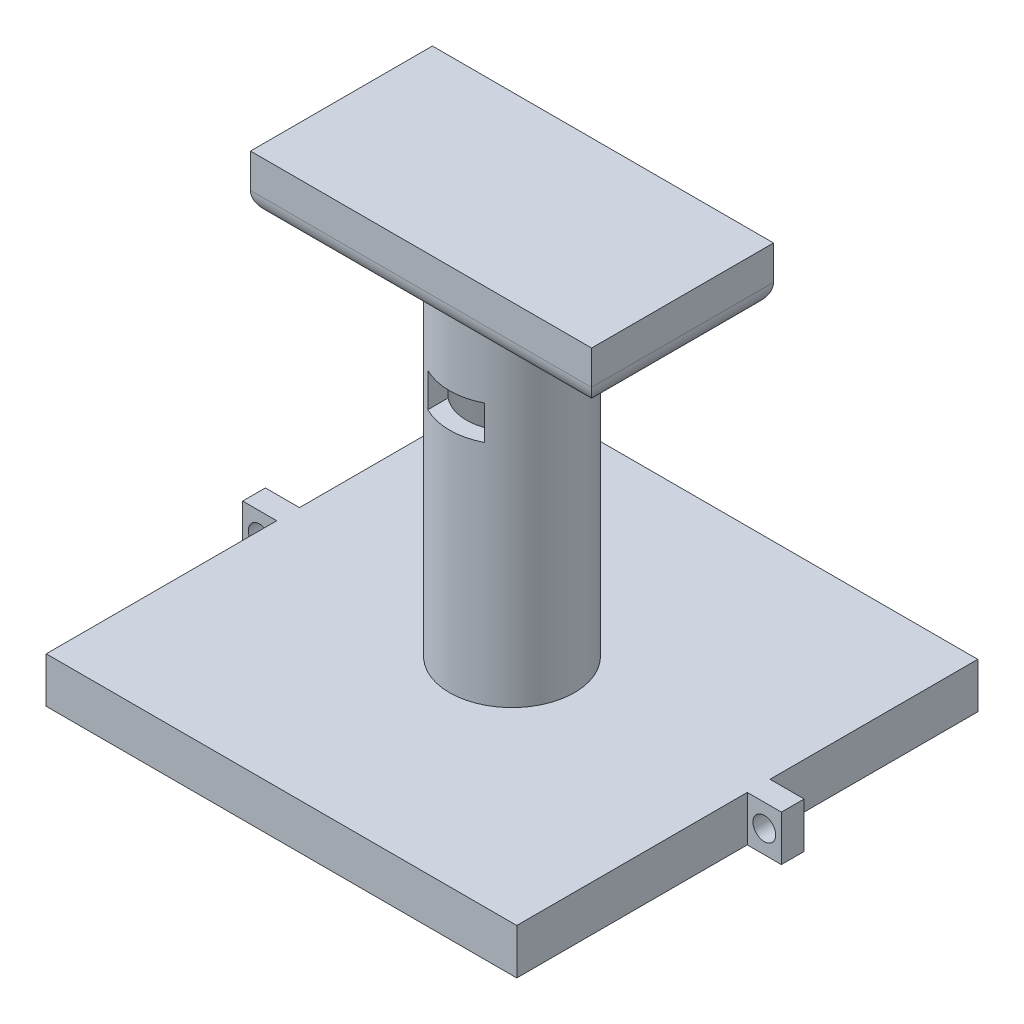
from build123d import *

# Parameters (mm, degrees)
SKETCH2_W           = 52.5507204
SKETCH2_H           = 51.48598542
SKETCH2_W_2         = 3.81
SKETCH2_H_2         = 2.54
BOSS_EXTRUDE1_DEPTH = 5.08
SKETCH3_W           = 47.4707204
SKETCH3_H           = 46.40598542
CUT_EXTRUDE1_DEPTH  = 3.81
SKETCH4_R           = 1.27
CUT_EXTRUDE2_DEPTH  = 3.302
SKETCH5_R           = 5.08
CUT_EXTRUDE3_DEPTH  = 1.9304
SKETCH6_R           = 6.985
BOSS_EXTRUDE2_DEPTH = 38.1
SKETCH8_R           = 5.08
CUT_EXTRUDE4_DEPTH  = 38.1
SKETCH7_W           = 38.1
SKETCH7_H           = 20.32
BOSS_EXTRUDE3_DEPTH = 6.35
FILLET3_R           = 2.54
SKETCH9_W           = 6.35
SKETCH9_H           = 3.81
CUT_EXTRUDE5_DEPTH  = 11.938


with BuildPart() as part:
    # Sketch2 → Boss-Extrude1 (new body)
    with BuildSketch(Plane(origin=(0, 0, 0), x_dir=(1, 0, 0), z_dir=(0, 1, 0))):
        with Locations((0, 3.81e-06)):
            Rectangle(SKETCH2_W, SKETCH2_H)
        with Locations((28.1803602, 1.27)):
            Rectangle(SKETCH2_W_2, SKETCH2_H_2)
        with Locations((-28.1803602, 1.2700127)):
            Rectangle(SKETCH2_W_2, SKETCH2_H_2)
    extrude(amount=BOSS_EXTRUDE1_DEPTH)

    # Sketch3 → Cut-Extrude1 (cut)
    with BuildSketch(Plane.XZ):
        with Locations((0, -3.81e-06)):
            Rectangle(SKETCH3_W, SKETCH3_H)
    extrude(amount=-CUT_EXTRUDE1_DEPTH, mode=Mode.SUBTRACT)

    # Sketch4 → Cut-Extrude2 (cut)
    with BuildSketch(Plane.XY):
        with Locations((28.1803602, 2.54)):
            Circle(SKETCH4_R)
        with Locations((-28.1803602, 2.54)):
            Circle(SKETCH4_R)
    extrude(amount=-CUT_EXTRUDE2_DEPTH, mode=Mode.SUBTRACT)

    # Sketch5 → Cut-Extrude3 (cut)
    with BuildSketch(Plane(origin=(0, 5.08, 0), x_dir=(1, 0, 0), z_dir=(0, 1, 0))):
        Circle(SKETCH5_R)
    extrude(amount=-CUT_EXTRUDE3_DEPTH, mode=Mode.SUBTRACT)

    # Sketch6 → Boss-Extrude2 (add)
    with BuildSketch(Plane(origin=(0, 5.08, 0), x_dir=(1, 0, 0), z_dir=(0, 1, 0))):
        Circle(SKETCH6_R)
    extrude(amount=BOSS_EXTRUDE2_DEPTH)

    # Sketch8 → Cut-Extrude4 (cut)
    with BuildSketch(Plane(origin=(0, 43.18, 0), x_dir=(1, 0, 0), z_dir=(0, 1, 0))):
        Circle(SKETCH8_R)
    extrude(amount=-CUT_EXTRUDE4_DEPTH, mode=Mode.SUBTRACT)

    # Sketch7 → Boss-Extrude3 (add)
    with BuildSketch(Plane(origin=(0, 43.18, 0), x_dir=(1, 0, 0), z_dir=(0, 1, 0))):
        Rectangle(SKETCH7_W, SKETCH7_H)
    extrude(amount=BOSS_EXTRUDE3_DEPTH)

    # Fillet3
    fillet3_edges = [part.edges().sort_by_distance(p)[0] for p in [
        (-19.05, 43.18, 0),
        (0, 43.18, 10.16),
        (19.05, 43.18, 0),
        (0, 43.18, -10.16),
    ]]
    fillet(fillet3_edges, radius=FILLET3_R)

    # Sketch9 → Cut-Extrude5 (cut)
    with BuildSketch(Plane.XY.offset(0.3429889)):
        with Locations((0, 32.385)):
            Rectangle(SKETCH9_W, SKETCH9_H)
    extrude(amount=CUT_EXTRUDE5_DEPTH, mode=Mode.SUBTRACT)


solid = part.part
